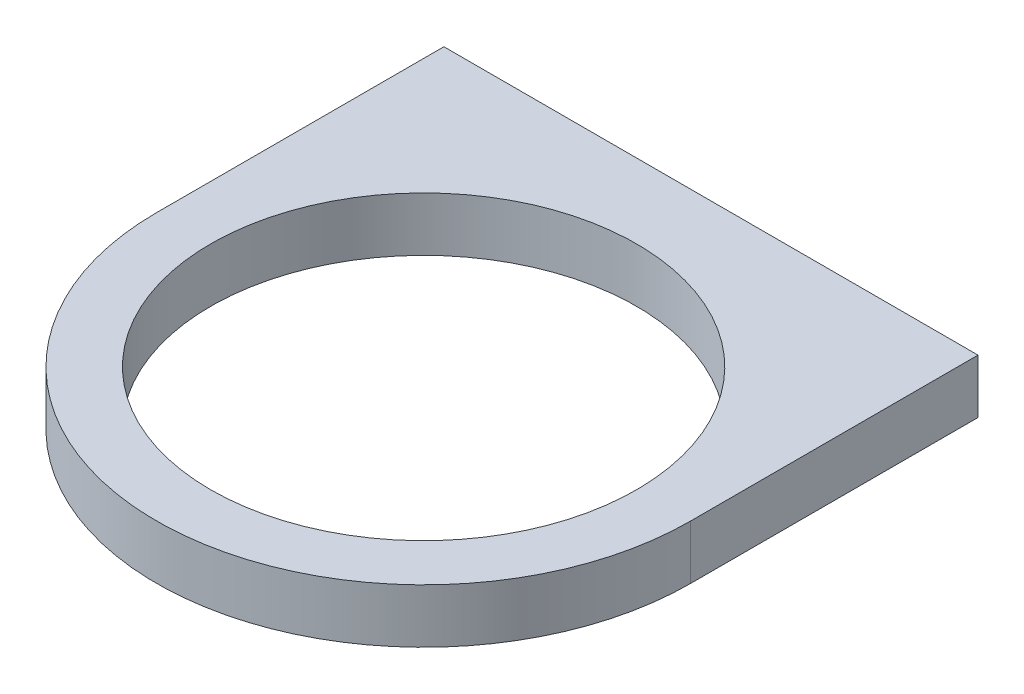
from build123d import *

# Parameters (mm, degrees)
SKETCH18_R           = 31.5
BOSS_EXTRUDE13_DEPTH = 8
SKETCH19_R           = 2
BOSS_EXTRUDE14_DEPTH = 2


with BuildPart() as part:
    # Sketch18 → Boss-Extrude13 (new body)
    with BuildSketch(Plane(origin=(0, 0, 0), x_dir=(1, 0, 0), z_dir=(0, 1, 0))):
        with BuildLine():
            Line((-39.5, 0), (-39.5, 42.5))
            Line((-39.5, 42.5), (39.5, 42.5))
            Line((39.5, 42.5), (39.5, 0))
            ThreePointArc((39.5, 0), (0, -39.5), (-39.5, 0))
        make_face()
        Circle(SKETCH18_R, mode=Mode.SUBTRACT)
    extrude(amount=BOSS_EXTRUDE13_DEPTH)

    # Sketch19 → Boss-Extrude14 (add)
    with BuildSketch(Plane.XZ):
        with Locations((-35.5, -38.5)):
            Circle(SKETCH19_R)
        with Locations((35.5, -38.5)):
            Circle(SKETCH19_R)
    extrude(amount=BOSS_EXTRUDE14_DEPTH)


solid = part.part
